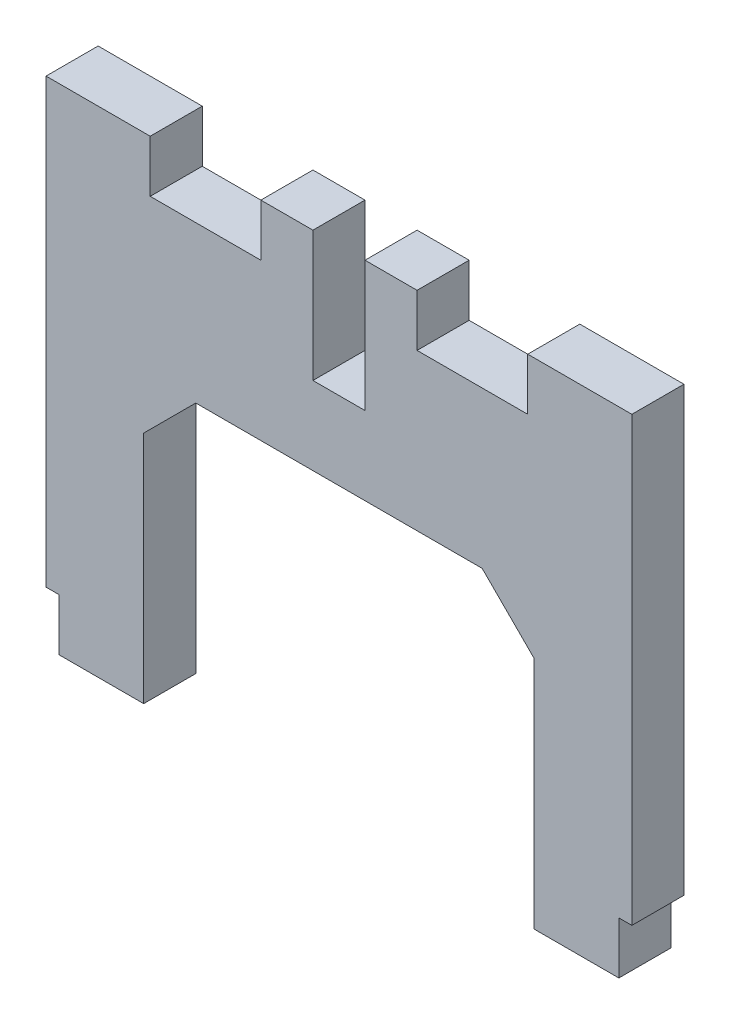
from build123d import *

# Parameters (mm, degrees)
BOSS_EXTRUDE1_DEPTH      = 4
CHAMFER2_SIZE            = 4
CHAMFER2_OF_MIRROR1_SIZE = 4
SKETCH2_W                = 4
SKETCH2_H                = 4
SKETCH2_W_2              = 8
BOSS_EXTRUDE2_DEPTH      = 4


with BuildPart() as part:
    # Sketch1 → Boss-Extrude1 (new body)
    with BuildSketch(Plane.XY):
        Polygon((0, 0), (0, 30), (-20.5, 30), (-20.5, 24), (-22.5, 24), (-22.5, 18), (-7.5, 18), (-7.5, -4), (-1, -4), (-1, 0), align=None)
    boss_extrude1 = extrude(amount=BOSS_EXTRUDE1_DEPTH)

    # Chamfer2
    chamfer2_edges = [part.edges().sort_by_distance(p)[0] for p in [
        (-7.5, 18, 2),
    ]]
    chamfer(chamfer2_edges, length=CHAMFER2_SIZE)

    # Mirror1: Boss-Extrude1 across plane
    add(boss_extrude1.mirror(Plane(origin=(-22.5, 24, 4), x_dir=(0, 0, 1), z_dir=(1, 0, 0))))

    # Chamfer2 of Mirror1
    chamfer2_of_mirror1_edges = [part.edges().sort_by_distance(p)[0] for p in [
        (-37.5, 18, 2),
    ]]
    chamfer(chamfer2_of_mirror1_edges, length=CHAMFER2_OF_MIRROR1_SIZE)

    # Sketch2 → Boss-Extrude2 (add)
    with BuildSketch(Plane.XY.offset(4)):
        with Locations((-26.5, 32)):
            Rectangle(SKETCH2_W, SKETCH2_H)
        with Locations((-18.5, 32)):
            Rectangle(SKETCH2_W, SKETCH2_H)
        with Locations((-4, 32)):
            Rectangle(SKETCH2_W_2, SKETCH2_H)
        with Locations((-41, 32)):
            Rectangle(SKETCH2_W_2, SKETCH2_H)
    extrude(amount=-BOSS_EXTRUDE2_DEPTH)


solid = part.part
